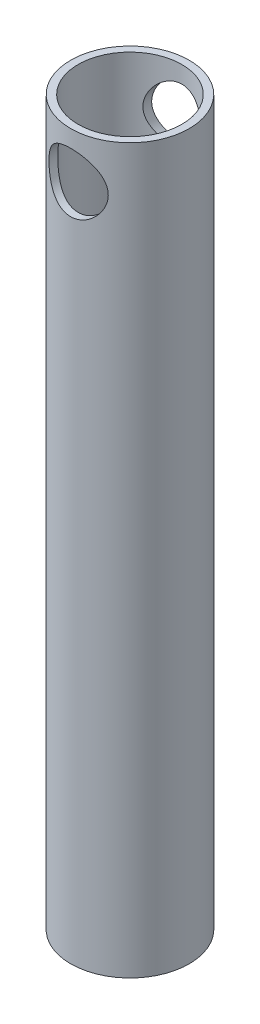
from build123d import *

# Parameters (mm, degrees)
SKETCH1_R               = 12.7
SKETCH1_R_2             = 11.1125
EXTRUDE_THIN1_DEPTH     = 155
SKETCH2_R               = 6.35
CUT_EXTRUDE1_DEPTH      = 13.7
CUT_EXTRUDE1_DEPTH_BACK = 13.7


with BuildPart() as part:
    # Sketch1 → Extrude-Thin1 (new body)
    with BuildSketch(Plane(origin=(0, 0, 0), x_dir=(1, 0, 0), z_dir=(0, 1, 0))):
        Circle(SKETCH1_R)
        Circle(SKETCH1_R_2, mode=Mode.SUBTRACT)
    extrude(amount=EXTRUDE_THIN1_DEPTH)

    # Sketch2 → Cut-Extrude1 (cut, two sides)
    with BuildSketch(Plane.XY) as cut_extrude1_sk:
        with Locations((0, 145)):
            Circle(SKETCH2_R)
    extrude(amount=CUT_EXTRUDE1_DEPTH, mode=Mode.SUBTRACT)
    extrude(cut_extrude1_sk.sketch, amount=-CUT_EXTRUDE1_DEPTH_BACK, mode=Mode.SUBTRACT)


solid = part.part
